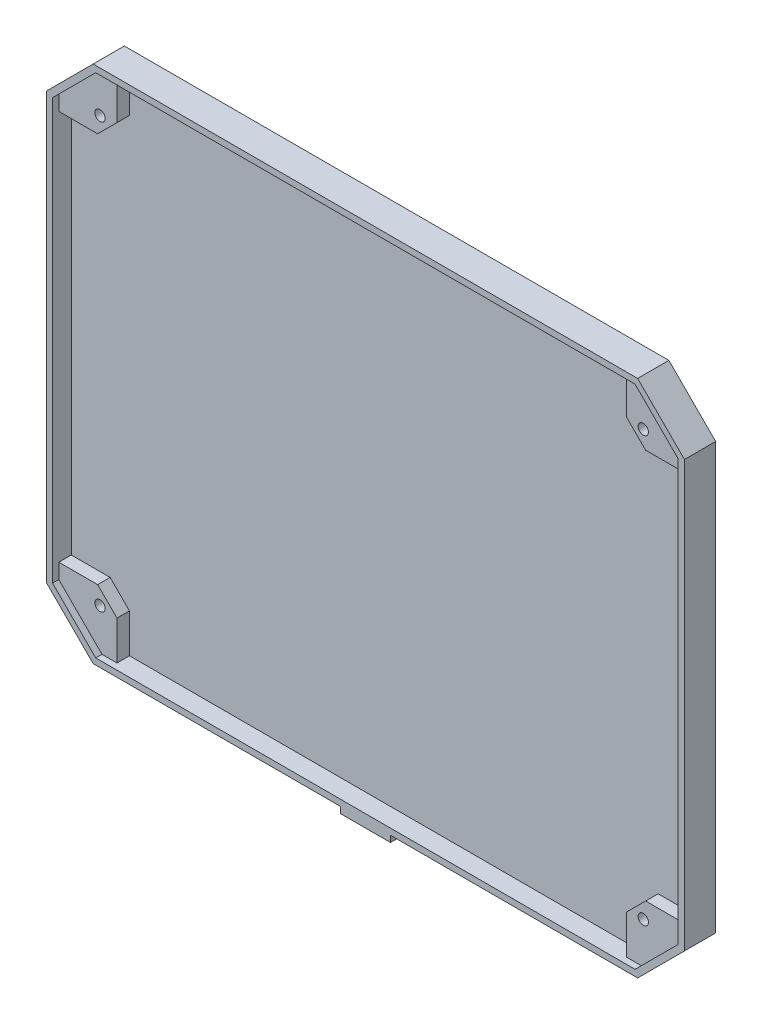
from build123d import *

# Parameters (mm, degrees)
ESQUISSE1_W             = 204.52
ESQUISSE1_H             = 166.42
BOSS_EXTRU_1_DEPTH      = 10
CHANFREIN1_SIZE         = 15
ENL_V_MAT_EXTRU_1_DEPTH = 2
ENL_V_MAT_EXTRU_2_DEPTH = 4
ESQUISSE4_R             = 1.65
ENL_V_MAT_EXTRU_3_DEPTH = 9
ESQUISSE5_R             = 3.8
ENL_V_MAT_EXTRU_4_DEPTH = 2.8
ESQUISSE6_W             = 16.1
ESQUISSE6_H             = 3
BOSS_EXTRU_2_DEPTH      = 2


with BuildPart() as part:
    # Esquisse1 → Boss.-Extru.1 (new body)
    with BuildSketch(Plane.XY):
        Rectangle(ESQUISSE1_W, ESQUISSE1_H)
    extrude(amount=BOSS_EXTRU_1_DEPTH)

    # Chanfrein1
    chanfrein1_edges = [part.edges().sort_by_distance(p)[0] for p in [
        (-102.26, 83.21, 5),
        (102.26, 83.21, 5),
        (102.26, -83.21, 5),
        (-102.26, -83.21, 5),
    ]]
    chamfer(chanfrein1_edges, length=CHANFREIN1_SIZE)

    # Esquisse2 → Enlèv. mat.-Extru.1 (cut)
    with BuildSketch(Plane.XY.offset(10)):
        Polygon((86.431572875, -81.21), (100.26, -67.381572875), (100.26, 67.381572875), (86.431572875, 81.21), (-86.431572875, 81.21), (-100.26, 67.381572875), (-100.26, -67.381572875), (-86.431572875, -81.21), align=None)
    extrude(amount=-ENL_V_MAT_EXTRU_1_DEPTH, mode=Mode.SUBTRACT)

    # Esquisse3 → Enlèv. mat.-Extru.2 (cut)
    with BuildSketch(Plane.XY.offset(8)):
        Polygon((-81.611572875, 81.21), (-81.611572875, 68.762452403), (-87.812452403, 62.561572875), (-100.26, 62.561572875), (-100.26, -62.561572875), (-87.812452403, -62.561572875), (-81.611572875, -68.762452403), (-81.611572875, -81.21), (81.611572875, -81.21), (81.611572875, -68.762452403), (87.812452403, -62.561572875), (100.26, -62.561572875), (100.26, 62.561572875), (87.812452403, 62.561572875), (81.611572875, 68.762452403), (81.611572875, 81.21), align=None)
    extrude(amount=-ENL_V_MAT_EXTRU_2_DEPTH, mode=Mode.SUBTRACT)

    # Esquisse4 → Enlèv. mat.-Extru.3 (cut, through all)
    with BuildSketch(Plane.XY.offset(8)):
        with Locations((-87.06, 68.01)):
            Circle(ESQUISSE4_R)
        with Locations((-87.06, -68.01)):
            Circle(ESQUISSE4_R)
        with Locations((87.06, -68.01)):
            Circle(ESQUISSE4_R)
        with Locations((87.06, 68.01)):
            Circle(ESQUISSE4_R)
    extrude(amount=-ENL_V_MAT_EXTRU_3_DEPTH, mode=Mode.SUBTRACT)

    # Esquisse5 → Enlèv. mat.-Extru.4 (cut)
    with BuildSketch(Plane(origin=(0, 0, 0), x_dir=(-1, 0, 0), z_dir=(0, 0, -1))):
        with Locations((87.06, 68.01)):
            Circle(ESQUISSE5_R)
        with Locations((-87.06, 68.01)):
            Circle(ESQUISSE5_R)
        with Locations((-87.06, -68.01)):
            Circle(ESQUISSE5_R)
        with Locations((87.06, -68.01)):
            Circle(ESQUISSE5_R)
    extrude(amount=-ENL_V_MAT_EXTRU_4_DEPTH, mode=Mode.SUBTRACT)

    # Esquisse6 → Boss.-Extru.2 (add)
    with BuildSketch(Plane.XZ.offset(83.21)):
        with Locations((0, 8.5)):
            Rectangle(ESQUISSE6_W, ESQUISSE6_H)
    extrude(amount=BOSS_EXTRU_2_DEPTH)


solid = part.part
